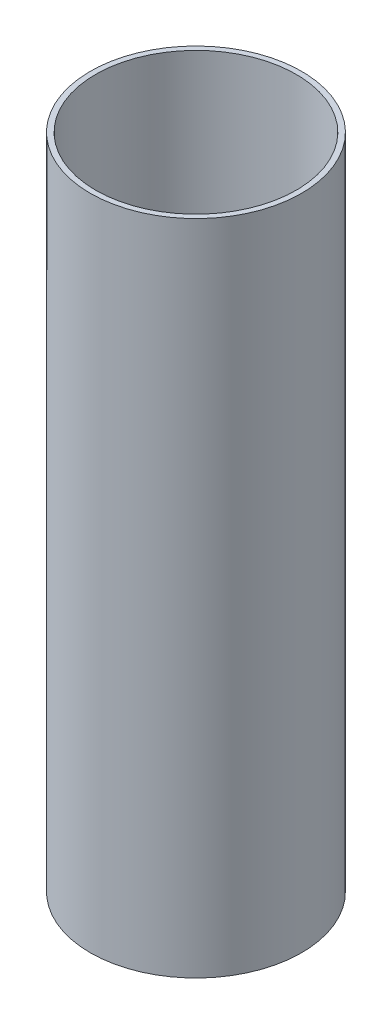
from build123d import *

# Parameters (mm, degrees)
SKETCH1_R           = 32.1437
SKETCH1_R_2         = 30.5181
BOSS_EXTRUDE1_DEPTH = 200.025


with BuildPart() as part:
    # Sketch1 → Boss-Extrude1 (new body)
    with BuildSketch(Plane(origin=(0, 0, 0), x_dir=(1, 0, 0), z_dir=(0, 1, 0))):
        Circle(SKETCH1_R)
        Circle(SKETCH1_R_2, mode=Mode.SUBTRACT)
    extrude(amount=BOSS_EXTRUDE1_DEPTH)


solid = part.part
